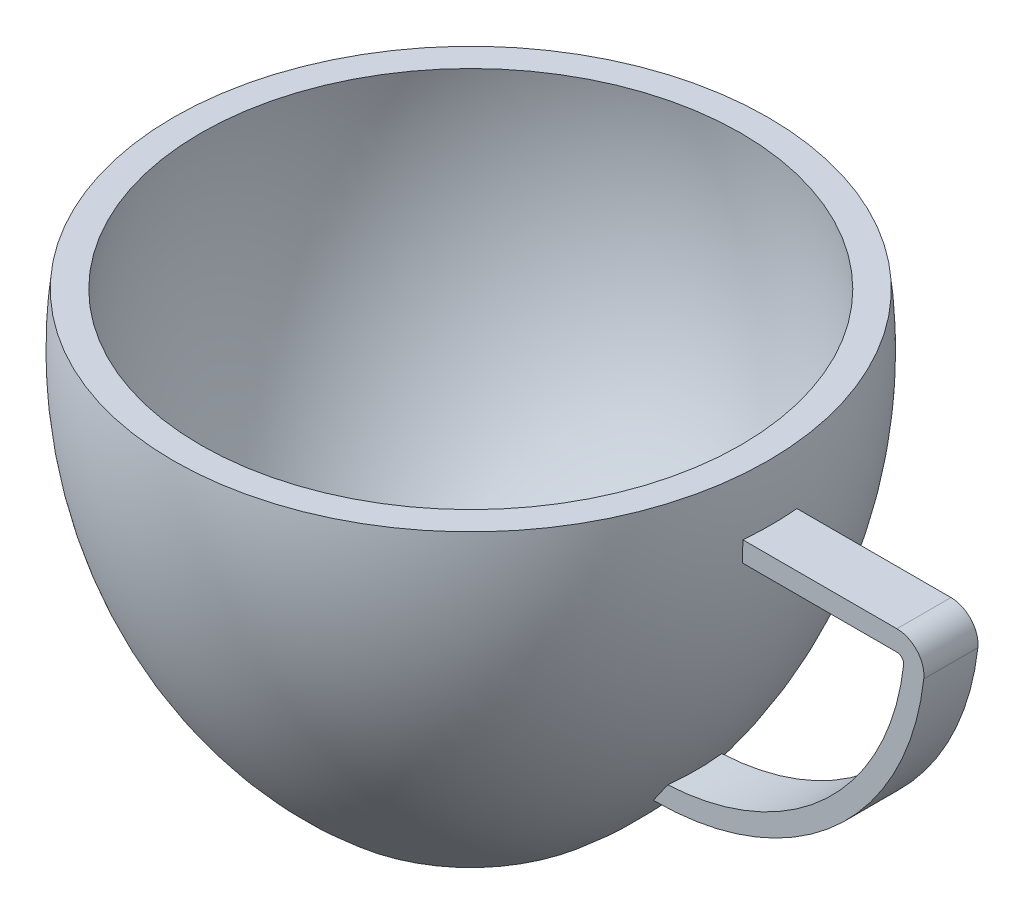
from build123d import *

# Parameters (mm, degrees)
EXTRUDE_THIN1_DEPTH = 1


with BuildPart() as part:
    # Sketch1 → Revolve1 (revolve)
    with BuildSketch(Plane.XY):
        with BuildLine():
            Line((0, 0), (0, 15))
            Line((0, 15), (-11, 15))
            ThreePointArc((-11, 15), (-9.895693792, 6.741722483), (-5, 0))
            Line((-5, 0), (0, 0))
        make_face()
    revolve(axis=Axis((0, 0, 0), (0, 1, 0)))

    # Sketch2 → Cut-Revolve1 (revolve, cut)
    with BuildSketch(Plane.XY):
        with BuildLine():
            Line((-4.631485449, 1), (0, 1))
            Line((0, 1), (0, 15))
            Line((0, 15), (-9.990391357, 15.020985748))
            ThreePointArc((-9.990391357, 15.020985748), (-9.998621935, 14.953314924), (-10.00656412, 14.885609646))
            ThreePointArc((-10.00656412, 14.885609646), (-9.032678183, 7.279454631), (-4.631485449, 1))
        make_face()
    revolve(axis=Axis((0, 0, 0), (0, 1, 0)), mode=Mode.SUBTRACT)

    # Sketch4 → Extrude-Thin1 (add, symmetric)
    with BuildSketch(Plane.XY):
        with BuildLine():
            Line((10.5, 13), (16.763146706, 13))
            ThreePointArc((16.763146706, 13), (17.508502699, 12.666666667), (17.756954696, 11.888888889))
            ThreePointArc((17.756954696, 11.888888889), (14.485541463, 5.546440075), (7.818874796, 3))
            Line((7.818874796, 3), (7.314252508, 3))
            Line((7.314252508, 3), (7.314252508, 3.75))
            Line((7.314252508, 3.75), (7.818874796, 3.75))
            ThreePointArc((7.818874796, 3.75), (13.985541463, 6.105457069), (17.011598704, 11.972222222))
            ThreePointArc((17.011598704, 11.972222222), (16.949485704, 12.166666667), (16.763146706, 12.25))
            Line((16.763146706, 12.25), (10.5, 12.25))
            Line((10.5, 12.25), (10.5, 13))
        make_face()
    extrude(amount=EXTRUDE_THIN1_DEPTH, both=True)


solid = part.part
